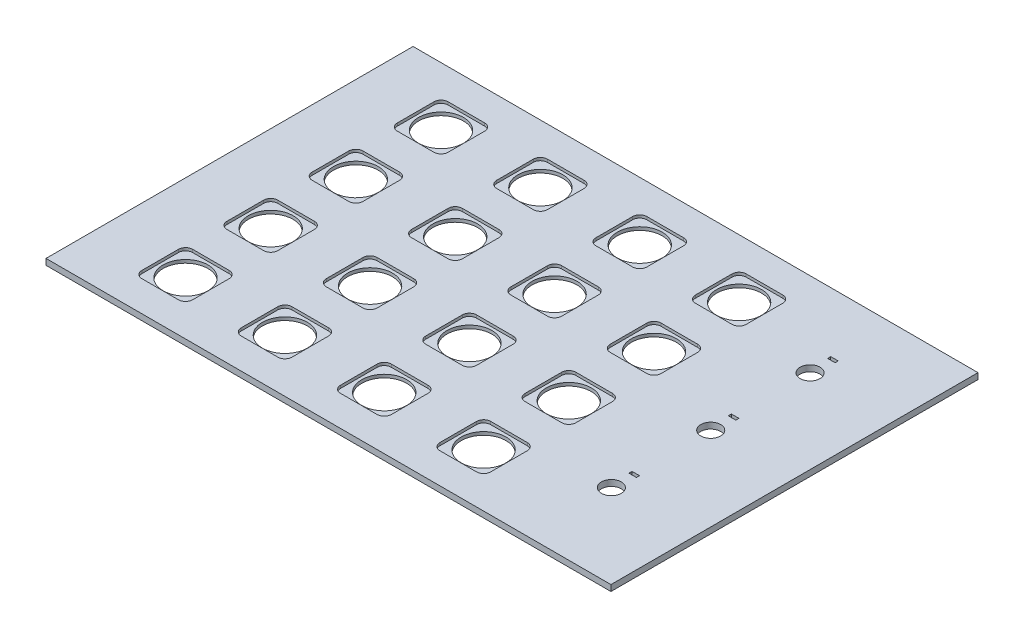
from build123d import *

# Parameters (mm, degrees)
SKETCH1_W           = 199
SKETCH1_H           = 129.3
SKETCH1_R           = 7.9
SKETCH1_R_2         = 3.5
SKETCH1_W_2         = 2.65
SKETCH1_H_2         = 1.1
BOSS_EXTRUDE1_DEPTH = 2.13
SKETCH2_W           = 17.9
SKETCH2_H           = 17.9
CUT_EXTRUDE1_DEPTH  = 1
FILLET1_R           = 2.5


with BuildPart() as part:
    # Sketch1 → Boss-Extrude1 (new body)
    with BuildSketch(Plane(origin=(0, 0, 0), x_dir=(1, 0, 0), z_dir=(0, 1, 0))):
        Rectangle(SKETCH1_W, SKETCH1_H)
        with Locations((-70, 45)):
            Circle(SKETCH1_R, mode=Mode.SUBTRACT)
        with Locations((-35, 45)):
            Circle(SKETCH1_R, mode=Mode.SUBTRACT)
        with Locations((0, 45)):
            Circle(SKETCH1_R, mode=Mode.SUBTRACT)
        with Locations((35, 45)):
            Circle(SKETCH1_R, mode=Mode.SUBTRACT)
        with Locations((-35, 15)):
            Circle(SKETCH1_R, mode=Mode.SUBTRACT)
        with Locations((0, 15)):
            Circle(SKETCH1_R, mode=Mode.SUBTRACT)
        with Locations((35, 15)):
            Circle(SKETCH1_R, mode=Mode.SUBTRACT)
        with Locations((-35, -15)):
            Circle(SKETCH1_R, mode=Mode.SUBTRACT)
        with Locations((0, -15)):
            Circle(SKETCH1_R, mode=Mode.SUBTRACT)
        with Locations((35, -15)):
            Circle(SKETCH1_R, mode=Mode.SUBTRACT)
        with Locations((-35, -45)):
            Circle(SKETCH1_R, mode=Mode.SUBTRACT)
        with Locations((0, -45)):
            Circle(SKETCH1_R, mode=Mode.SUBTRACT)
        with Locations((35, -45)):
            Circle(SKETCH1_R, mode=Mode.SUBTRACT)
        with Locations((-70, 15)):
            Circle(SKETCH1_R, mode=Mode.SUBTRACT)
        with Locations((-70, -15)):
            Circle(SKETCH1_R, mode=Mode.SUBTRACT)
        with Locations((-70, -45)):
            Circle(SKETCH1_R, mode=Mode.SUBTRACT)
        with Locations((70, 35)):
            Circle(SKETCH1_R_2, mode=Mode.SUBTRACT)
        with Locations((70, 0)):
            Circle(SKETCH1_R_2, mode=Mode.SUBTRACT)
        with Locations((70, -35)):
            Circle(SKETCH1_R_2, mode=Mode.SUBTRACT)
        with Locations((70, 43.05)):
            Rectangle(SKETCH1_W_2, SKETCH1_H_2, mode=Mode.SUBTRACT)
        with Locations((70, 8.05)):
            Rectangle(SKETCH1_W_2, SKETCH1_H_2, mode=Mode.SUBTRACT)
        with Locations((70, -26.95)):
            Rectangle(SKETCH1_W_2, SKETCH1_H_2, mode=Mode.SUBTRACT)
    extrude(amount=BOSS_EXTRUDE1_DEPTH)

    # Sketch2 → Cut-Extrude1 (cut)
    with BuildSketch(Plane(origin=(0, 2.13, 0), x_dir=(1, 0, 0), z_dir=(0, 1, 0))):
        with Locations((-70, 45)):
            Rectangle(SKETCH2_W, SKETCH2_H)
        with Locations((-35, 45)):
            Rectangle(SKETCH2_W, SKETCH2_H)
        with Locations((0, 45)):
            Rectangle(SKETCH2_W, SKETCH2_H)
        with Locations((35, 45)):
            Rectangle(SKETCH2_W, SKETCH2_H)
        with Locations((-35, 15)):
            Rectangle(SKETCH2_W, SKETCH2_H)
        with Locations((0, 15)):
            Rectangle(SKETCH2_W, SKETCH2_H)
        with Locations((35, 15)):
            Rectangle(SKETCH2_W, SKETCH2_H)
        with Locations((-35, -15)):
            Rectangle(SKETCH2_W, SKETCH2_H)
        with Locations((0, -15)):
            Rectangle(SKETCH2_W, SKETCH2_H)
        with Locations((35, -15)):
            Rectangle(SKETCH2_W, SKETCH2_H)
        with Locations((-35, -45)):
            Rectangle(SKETCH2_W, SKETCH2_H)
        with Locations((0, -45)):
            Rectangle(SKETCH2_W, SKETCH2_H)
        with Locations((35, -45)):
            Rectangle(SKETCH2_W, SKETCH2_H)
        with Locations((-70, 15)):
            Rectangle(SKETCH2_W, SKETCH2_H)
        with Locations((-70, -15)):
            Rectangle(SKETCH2_W, SKETCH2_H)
        with Locations((-70, -45)):
            Rectangle(SKETCH2_W, SKETCH2_H)
    extrude(amount=-CUT_EXTRUDE1_DEPTH, mode=Mode.SUBTRACT)

    # Fillet1
    fillet1_edges = [part.edges().sort_by_distance(p)[0] for p in [
        (-8.95, 1.63, 23.95),
        (-8.95, 1.63, 6.05),
        (8.95, 1.63, 6.05),
        (8.95, 1.63, 23.95),
        (-43.95, 1.63, 23.95),
        (-43.95, 1.63, 6.05),
        (-26.05, 1.63, 6.05),
        (-26.05, 1.63, 23.95),
        (26.05, 1.63, -6.05),
        (26.05, 1.63, -23.95),
        (43.95, 1.63, -23.95),
        (43.95, 1.63, -6.05),
        (-8.95, 1.63, -6.05),
        (-8.95, 1.63, -23.95),
        (8.95, 1.63, -23.95),
        (8.95, 1.63, -6.05),
        (-43.95, 1.63, -36.05),
        (-43.95, 1.63, -53.95),
        (-26.05, 1.63, -53.95),
        (-26.05, 1.63, -36.05),
        (-8.95, 1.63, -36.05),
        (-8.95, 1.63, -53.95),
        (8.95, 1.63, -53.95),
        (8.95, 1.63, -36.05),
        (26.05, 1.63, -36.05),
        (26.05, 1.63, -53.95),
        (43.95, 1.63, -53.95),
        (43.95, 1.63, -36.05),
        (-43.95, 1.63, -6.05),
        (-43.95, 1.63, -23.95),
        (-26.05, 1.63, -23.95),
        (-26.05, 1.63, -6.05),
        (26.05, 1.63, 53.95),
        (26.05, 1.63, 36.05),
        (43.95, 1.63, 36.05),
        (43.95, 1.63, 53.95),
        (-8.95, 1.63, 53.95),
        (-8.95, 1.63, 36.05),
        (8.95, 1.63, 36.05),
        (8.95, 1.63, 53.95),
        (-43.95, 1.63, 53.95),
        (-43.95, 1.63, 36.05),
        (-26.05, 1.63, 36.05),
        (-26.05, 1.63, 53.95),
        (26.05, 1.63, 23.95),
        (26.05, 1.63, 6.05),
        (43.95, 1.63, 6.05),
        (43.95, 1.63, 23.95),
        (-78.95, 1.63, -6.05),
        (-78.95, 1.63, -23.95),
        (-61.05, 1.63, -23.95),
        (-61.05, 1.63, -6.05),
        (-78.95, 1.63, 23.95),
        (-78.95, 1.63, 6.05),
        (-61.05, 1.63, 6.05),
        (-61.05, 1.63, 23.95),
        (-78.95, 1.63, 53.95),
        (-78.95, 1.63, 36.05),
        (-61.05, 1.63, 36.05),
        (-61.05, 1.63, 53.95),
        (-78.95, 1.63, -36.05),
        (-78.95, 1.63, -53.95),
        (-61.05, 1.63, -53.95),
        (-61.05, 1.63, -36.05),
    ]]
    fillet(fillet1_edges, radius=FILLET1_R)


solid = part.part
